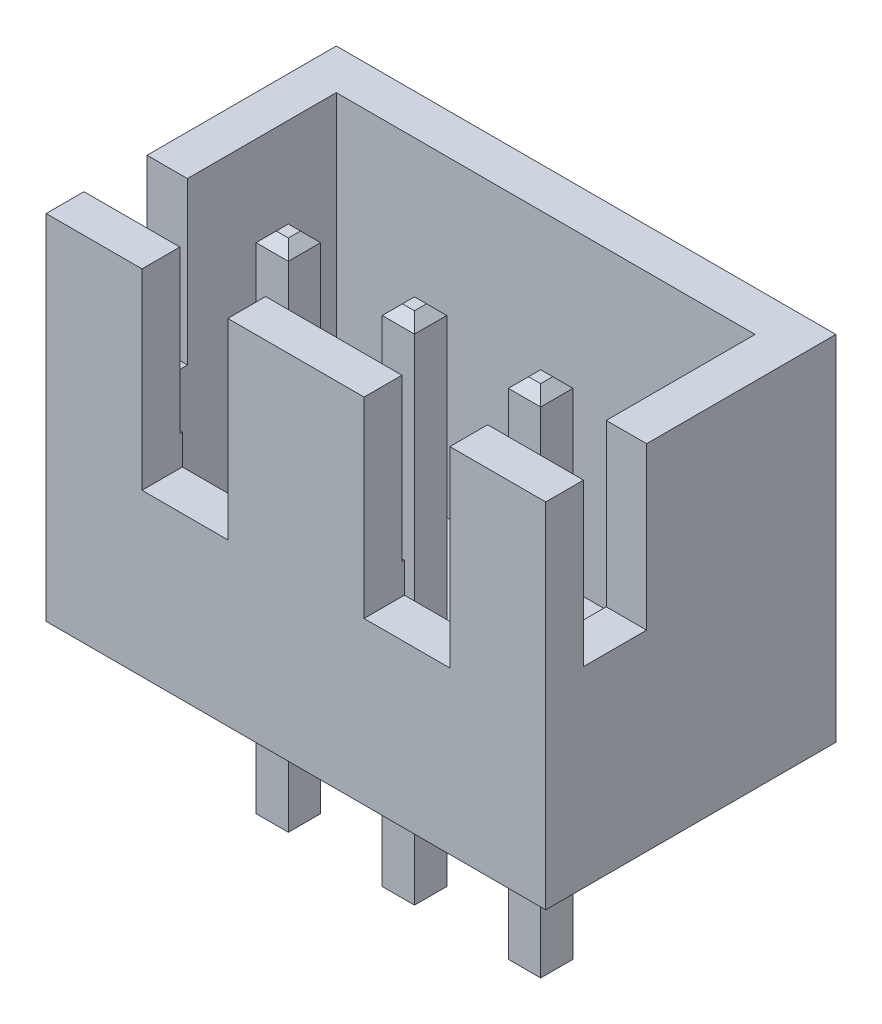
from build123d import *

# Parameters (mm, degrees)
SKETCH1_W                = 9.9
SKETCH1_H                = 5.75
BOSS_EXTRUDE1_DEPTH      = 7
SHELL1_T                 = -0.8
SKETCH2_W                = 1.25
SKETCH2_H                = 3.2
CUT_EXTRUDE1_DEPTH       = 10.9
CUT_EXTRUDE2_REACH       = 7.75
SKETCH3_W                = 1.7
SKETCH3_H                = 3.8
SKETCH4_W                = 0.64
SKETCH4_H                = 0.64
BOSS_EXTRUDE2_DEPTH      = 3.45
BOSS_EXTRUDE2_DEPTH_BACK = 6.75
CHAMFER1_SIZE            = 0.2


with BuildPart() as part:
    # Sketch1 → Boss-Extrude1 (new body)
    with BuildSketch(Plane(origin=(0, 0, 0), x_dir=(1, 0, 0), z_dir=(0, 1, 0))):
        Rectangle(SKETCH1_W, SKETCH1_H)
    extrude(amount=BOSS_EXTRUDE1_DEPTH)

    # Shell1
    shell1_openings = [part.faces().sort_by_distance(p)[0] for p in [
        (0, 7, 0),
    ]]
    offset(amount=SHELL1_T, openings=shell1_openings, kind=Kind.INTERSECTION)

    # Sketch2 → Cut-Extrude1 (cut, through all)
    with BuildSketch(Plane(origin=(4.95, 0, 0), x_dir=(0, 0, -1), z_dir=(1, 0, 0))):
        with Locations((-1.5, 5.4)):
            Rectangle(SKETCH2_W, SKETCH2_H)
    extrude(amount=-CUT_EXTRUDE1_DEPTH, mode=Mode.SUBTRACT)

    # Sketch3 → Cut-Extrude2 (cut, up to next)
    with BuildSketch(Plane.XY.offset(2.875), mode=Mode.PRIVATE) as cut_extrude2_sk1:
        with Locations((-2.2, 5.1)):
            Rectangle(SKETCH3_W, SKETCH3_H)
    cut_extrude2_tool1 = extrude(cut_extrude2_sk1.sketch, amount=-CUT_EXTRUDE2_REACH, mode=Mode.PRIVATE) & part.part
    add(cut_extrude2_tool1.solids().sort_by_distance((-2.2, 5.1, 2.875))[0], mode=Mode.SUBTRACT)
    # Sketch3 → Cut-Extrude2 (cut, up to next)
    with BuildSketch(Plane.XY.offset(2.875), mode=Mode.PRIVATE) as cut_extrude2_sk2:
        with Locations((2.2, 5.1)):
            Rectangle(SKETCH3_W, SKETCH3_H)
    cut_extrude2_tool2 = extrude(cut_extrude2_sk2.sketch, amount=-CUT_EXTRUDE2_REACH, mode=Mode.PRIVATE) & part.part
    add(cut_extrude2_tool2.solids().sort_by_distance((2.2, 5.1, 2.875))[0], mode=Mode.SUBTRACT)

    # Sketch4 → Boss-Extrude2 (add, two sides)
    with BuildSketch(Plane.XZ) as boss_extrude2_sk:
        with Locations((-2.5, 0.525)):
            Rectangle(SKETCH4_W, SKETCH4_H)
        with Locations((0, 0.525)):
            Rectangle(SKETCH4_W, SKETCH4_H)
        with Locations((2.5, 0.525)):
            Rectangle(SKETCH4_W, SKETCH4_H)
    extrude(amount=BOSS_EXTRUDE2_DEPTH)
    extrude(boss_extrude2_sk.sketch, amount=-BOSS_EXTRUDE2_DEPTH_BACK)

    # Chamfer1
    chamfer1_edges = [part.edges().sort_by_distance(p)[0] for p in [
        (0.32, 6.75, 0.525),
        (0, 6.75, 0.205),
        (-0.32, 6.75, 0.525),
        (0, 6.75, 0.845),
        (0.32, -3.45, 0.525),
        (0, -3.45, 0.845),
        (-0.32, -3.45, 0.525),
        (0, -3.45, 0.205),
        (2.82, 6.75, 0.525),
        (2.5, 6.75, 0.205),
        (2.18, 6.75, 0.525),
        (2.5, 6.75, 0.845),
        (2.82, -3.45, 0.525),
        (2.5, -3.45, 0.845),
        (2.18, -3.45, 0.525),
        (2.5, -3.45, 0.205),
        (-2.18, 6.75, 0.525),
        (-2.5, 6.75, 0.205),
        (-2.82, 6.75, 0.525),
        (-2.5, 6.75, 0.845),
        (-2.18, -3.45, 0.525),
        (-2.5, -3.45, 0.845),
        (-2.82, -3.45, 0.525),
        (-2.5, -3.45, 0.205),
    ]]
    chamfer(chamfer1_edges, length=CHAMFER1_SIZE)


solid = part.part
